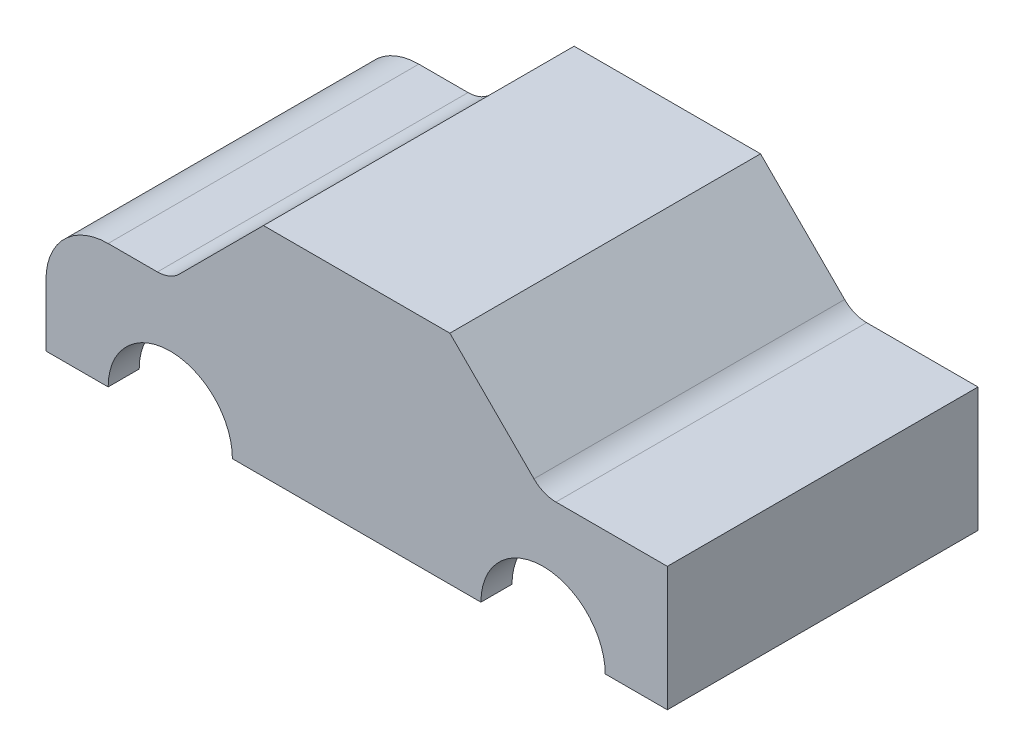
from build123d import *

# Parameters (mm, degrees)
BOSS_EXTRUDE1_DEPTH = 50
SHELL1_T            = -5
CUT_EXTRUDE1_DEPTH  = 51
SKETCH5_R           = 1.5
SKETCH5_R_2         = 0.75
CUT_EXTRUDE3_DEPTH  = 5
SKETCH6_W           = 1.5
SKETCH6_H           = 11
SKETCH6_W_2         = 8
BOSS_EXTRUDE2_DEPTH = 7.5
SKETCH8_W           = 8
SKETCH8_H           = 11
CUT_EXTRUDE5_DEPTH  = 3.5


with BuildPart() as part:
    # Sketch1 → Boss-Extrude1 (new body)
    with BuildSketch(Plane.XY):
        with BuildLine():
            Line((-50, 0), (50, 0))
            Line((50, 0), (50, 20))
            Line((50, 20), (32.071067812, 20))
            ThreePointArc((32.071067812, 20), (30.15765065, 20.380602337), (28.535533906, 21.464466094))
            Line((28.535533906, 21.464466094), (15, 35))
            Line((15, 35), (-15, 35))
            Line((-15, 35), (-28.535533906, 21.464466094))
            ThreePointArc((-28.535533906, 21.464466094), (-30.15765065, 20.380602337), (-32.071067812, 20))
            Line((-32.071067812, 20), (-40, 20))
            ThreePointArc((-40, 20), (-47.071067812, 17.071067812), (-50, 10))
            Line((-50, 10), (-50, 0))
        make_face()
    extrude(amount=BOSS_EXTRUDE1_DEPTH)

    # Shell1
    shell1_openings = [part.faces().sort_by_distance(p)[0] for p in [
        (0, 0, 25),
    ]]
    offset(amount=SHELL1_T, openings=shell1_openings, kind=Kind.INTERSECTION)

    # Sketch2 → Cut-Extrude1 (cut, through all)
    with BuildSketch(Plane.XY.offset(50)):
        with BuildLine():
            Line((-40, 0), (-20, 0))
            ThreePointArc((-20, 0), (-30, 10), (-40, 0))
        make_face()
        with BuildLine():
            Line((20, 0), (40, 0))
            ThreePointArc((40, 0), (30, 10), (20, 0))
        make_face()
    extrude(amount=-CUT_EXTRUDE1_DEPTH, mode=Mode.SUBTRACT)

    # Sketch5 → Cut-Extrude3 (cut)
    with BuildSketch(Plane.XZ):
        with Locations((-45, 3)):
            Circle(SKETCH5_R)
        with Locations((-45, 3)):
            Circle(SKETCH5_R_2, mode=Mode.SUBTRACT)
        with Locations((45, 3)):
            Circle(SKETCH5_R)
        with Locations((45, 3)):
            Circle(SKETCH5_R_2, mode=Mode.SUBTRACT)
        with Locations((45, 47)):
            Circle(SKETCH5_R)
        with Locations((45, 47)):
            Circle(SKETCH5_R_2, mode=Mode.SUBTRACT)
        with Locations((-45, 47)):
            Circle(SKETCH5_R)
        with Locations((-45, 47)):
            Circle(SKETCH5_R_2, mode=Mode.SUBTRACT)
    extrude(amount=-CUT_EXTRUDE3_DEPTH, mode=Mode.SUBTRACT)

    # Sketch6 → Boss-Extrude2 (add)
    with BuildSketch(Plane.XZ.offset(-15)):
        with Locations((17.5, 25)):
            Rectangle(SKETCH6_W, SKETCH6_H)
        with Locations((39.25, 25)):
            Rectangle(SKETCH6_W_2, SKETCH6_H)
    extrude(amount=BOSS_EXTRUDE2_DEPTH)

    # Sketch8 → Cut-Extrude5 (cut)
    with BuildSketch(Plane.XZ.offset(-7.5)):
        with Locations((39.25, 25)):
            Rectangle(SKETCH8_W, SKETCH8_H)
    extrude(amount=-CUT_EXTRUDE5_DEPTH, mode=Mode.SUBTRACT)


solid = part.part
